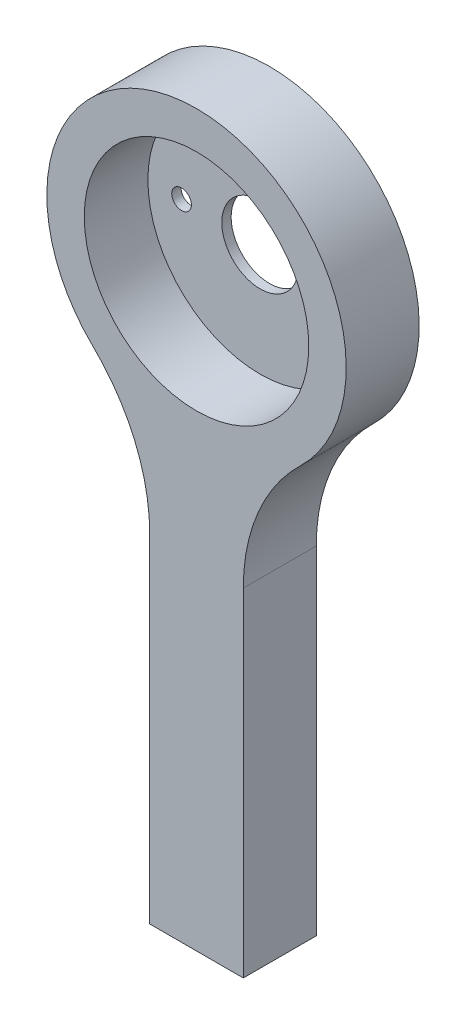
from build123d import *

# Parameters (mm, degrees)
SKETCH1_R           = 6
BOSS_EXTRUDE1_DEPTH = 3.9
SKETCH5_R           = 8
SKETCH5_R_2         = 2.05
SKETCH5_R_3         = 0.525
BOSS_EXTRUDE3_DEPTH = 0.5


with BuildPart() as part:
    # Sketch1 → Boss-Extrude1 (new body)
    with BuildSketch(Plane.XY):
        with BuildLine():
            Line((-2.5, -31), (2.5, -31))
            Line((2.5, -31), (2.5, -12.951833847))
            ThreePointArc((2.5, -12.951833847), (3.295532486, -9.043154047), (5.555555556, -5.756370599))
            ThreePointArc((5.555555556, -5.756370599), (0, 8), (-5.555555556, -5.756370599))
            ThreePointArc((-5.555555556, -5.756370599), (-3.295532486, -9.043154047), (-2.5, -12.951833847))
            Line((-2.5, -12.951833847), (-2.5, -31))
        make_face()
        Circle(SKETCH1_R, mode=Mode.SUBTRACT)
    extrude(amount=BOSS_EXTRUDE1_DEPTH)

    # Sketch5 → Boss-Extrude3 (add)
    with BuildSketch(Plane(origin=(0, 0, 0), x_dir=(-1, 0, 0), z_dir=(0, 0, -1))):
        Circle(SKETCH5_R)
        Circle(SKETCH5_R_2, mode=Mode.SUBTRACT)
        with Locations((4.2, 0)):
            Circle(SKETCH5_R_3, mode=Mode.SUBTRACT)
        with Locations((-4.2, 0)):
            Circle(SKETCH5_R_3, mode=Mode.SUBTRACT)
    extrude(amount=-BOSS_EXTRUDE3_DEPTH)


solid = part.part
